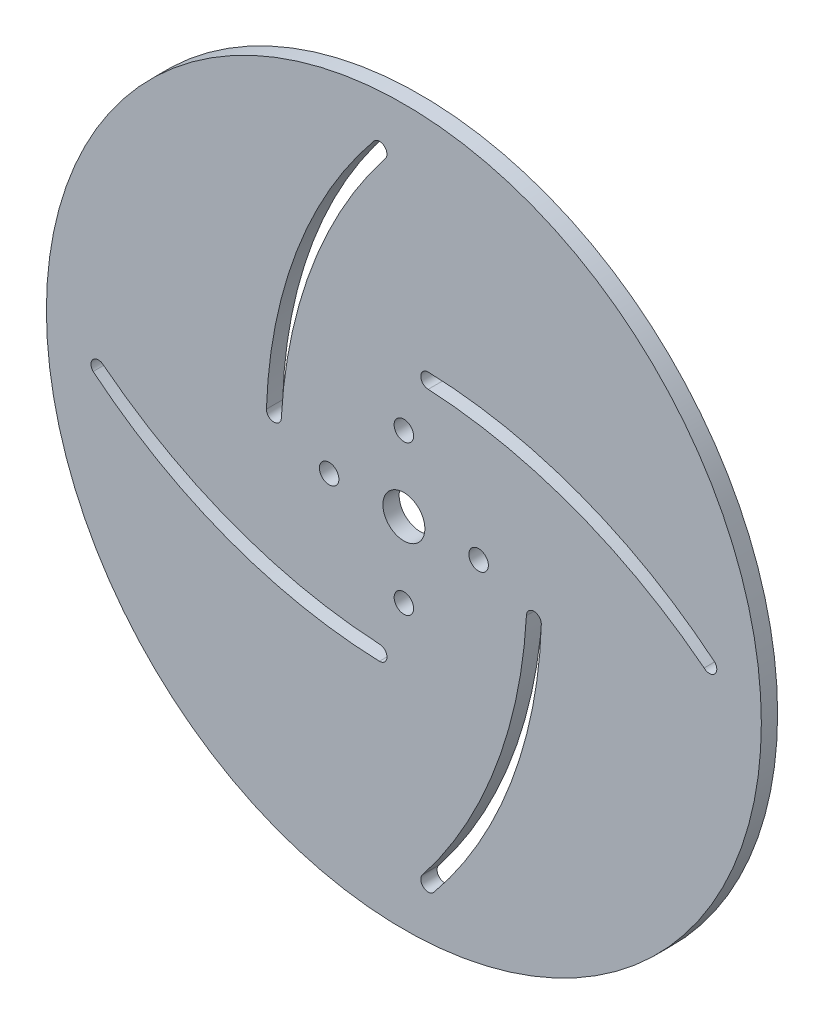
from build123d import *

# Parameters (mm, degrees)
SKETCH1_R           = 69.85
SKETCH1_R_2         = 4.1
BOSS_EXTRUDE1_DEPTH = 3.175
SKETCH4_R           = 1.905
CUT_EXTRUDE1_DEPTH  = 4.175


with BuildPart() as part:
    # Sketch1 → Boss-Extrude1 (new body)
    with BuildSketch(Plane.XY):
        Circle(SKETCH1_R)
        Circle(SKETCH1_R_2, mode=Mode.SUBTRACT)
        with BuildLine():
            ThreePointArc((60.715904818, 5.788404818), (34.486591453, 20.94201271), (4.777601385, 26.856792578))
            ThreePointArc((4.777601385, 26.856792578), (3.305570957, 25.407474231), (4.762499202, 23.942975224))
            ThreePointArc((4.762499202, 23.942975224), (33.266012569, 17.981736248), (58.664095182, 3.736595182))
            ThreePointArc((58.664095182, 3.736595182), (60.715904818, 3.736595182), (60.715904818, 5.788404818))
        make_face(mode=Mode.SUBTRACT)
        with BuildLine():
            ThreePointArc((-23.942975224, 4.762499202), (-17.981736248, 33.266012569), (-3.736595182, 58.664095182))
            ThreePointArc((-3.736595182, 58.664095182), (-3.736595182, 60.715904818), (-5.788404818, 60.715904818))
            ThreePointArc((-5.788404818, 60.715904818), (-20.94201271, 34.486591453), (-26.856792578, 4.777601385))
            ThreePointArc((-26.856792578, 4.777601385), (-25.407474231, 3.305570957), (-23.942975224, 4.762499202))
        make_face(mode=Mode.SUBTRACT)
        with BuildLine():
            ThreePointArc((5.788404818, -60.715904818), (20.94201271, -34.486591453), (26.856792578, -4.777601385))
            ThreePointArc((26.856792578, -4.777601385), (25.407474231, -3.305570957), (23.942975224, -4.762499202))
            ThreePointArc((23.942975224, -4.762499202), (17.981736248, -33.266012569), (3.736595182, -58.664095182))
            ThreePointArc((3.736595182, -58.664095182), (3.736595182, -60.715904818), (5.788404818, -60.715904818))
        make_face(mode=Mode.SUBTRACT)
        with BuildLine():
            ThreePointArc((-60.715904818, -5.788404818), (-34.486591453, -20.94201271), (-4.777601385, -26.856792578))
            ThreePointArc((-4.777601385, -26.856792578), (-3.305570957, -25.407474231), (-4.762499202, -23.942975224))
            ThreePointArc((-4.762499202, -23.942975224), (-33.266012569, -17.981736248), (-58.664095182, -3.736595182))
            ThreePointArc((-58.664095182, -3.736595182), (-60.715904818, -3.736595182), (-60.715904818, -5.788404818))
        make_face(mode=Mode.SUBTRACT)
    extrude(amount=BOSS_EXTRUDE1_DEPTH)

    # Sketch4 → Cut-Extrude1 (cut, through all)
    with BuildSketch(Plane.XY.offset(3.175)):
        with Locations((14.605, 0)):
            Circle(SKETCH4_R)
        with Locations((0, -14.605)):
            Circle(SKETCH4_R)
        with Locations((-14.605, 0)):
            Circle(SKETCH4_R)
        with Locations((0, 14.605)):
            Circle(SKETCH4_R)
    extrude(amount=-CUT_EXTRUDE1_DEPTH, mode=Mode.SUBTRACT)


solid = part.part
